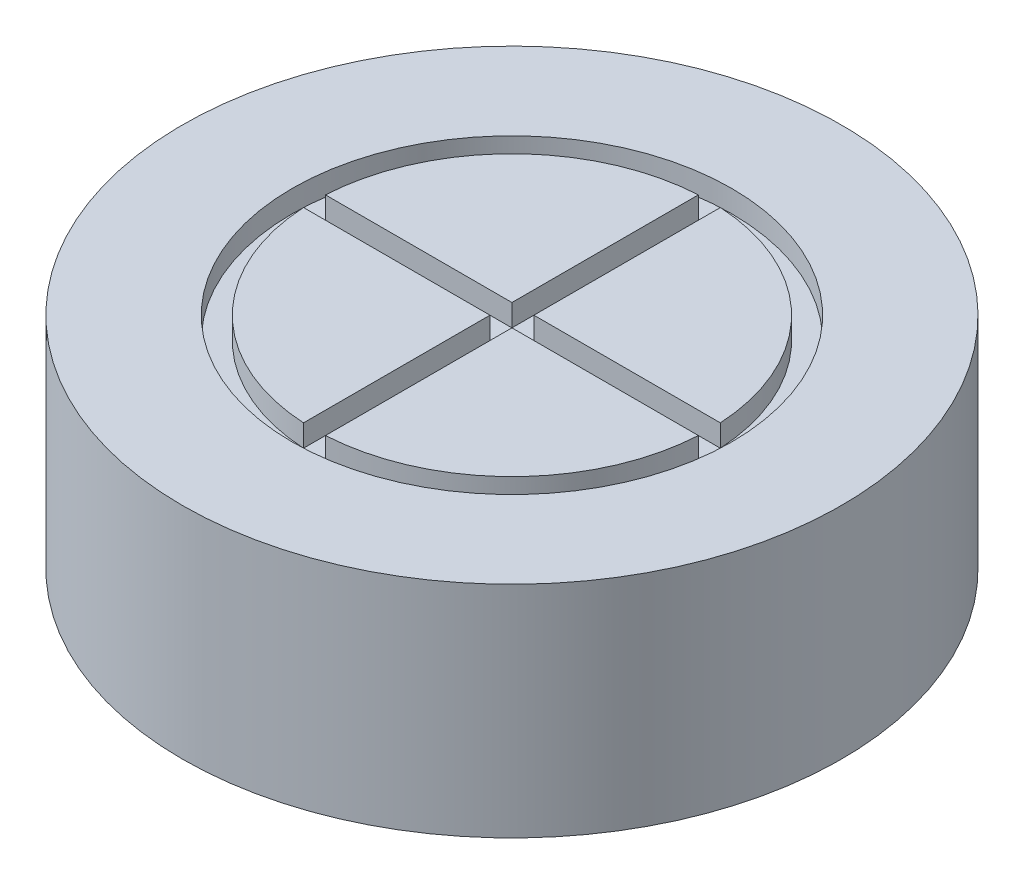
from build123d import *

# Parameters (mm, degrees)
SKETCH1_R           = 15
BOSS_EXTRUDE1_DEPTH = 10
SKETCH2_R           = 10
CUT_EXTRUDE1_DEPTH  = 1


with BuildPart() as part:
    # Sketch1 → Boss-Extrude1 (new body)
    with BuildSketch(Plane(origin=(0, 0, 0), x_dir=(1, 0, 0), z_dir=(0, 1, 0))):
        Circle(SKETCH1_R)
    extrude(amount=BOSS_EXTRUDE1_DEPTH)

    # Sketch3 → Cut-Revolve1 (revolve, cut)
    with BuildSketch(Plane(origin=(0, 0, 0), x_dir=(-1, 0, 0), z_dir=(0, -1, 0))):
        with BuildLine():
            Line((0, 5), (0, -5))
            ThreePointArc((0, -5), (5, 0), (0, 5))
        make_face()
    revolve(axis=Axis((0, 0, -5), (0, 0, 1)), mode=Mode.SUBTRACT)

    # Sketch2 → Cut-Extrude1 (cut)
    with BuildSketch(Plane(origin=(0, 10, 0), x_dir=(1, 0, 0), z_dir=(0, 1, 0))):
        Circle(SKETCH2_R)
        with BuildLine():
            Line((-0.5, -0.499807062), (-0.5, -8.986100378))
            ThreePointArc((-0.5, -8.986100378), (-6.36402935, -6.363892711), (-8.986111111, -0.499807062))
            Line((-8.986111111, -0.499807062), (-0.5, -0.499807062))
        make_face(mode=Mode.SUBTRACT)
        with BuildLine():
            Line((0.499807062, 8.986111111), (0.499807062, 0.499807062))
            Line((0.499807062, 0.499807062), (8.986111111, 0.499807062))
            ThreePointArc((8.986111111, 0.499807062), (6.363961031, 6.363961031), (0.499807062, 8.986111111))
        make_face(mode=Mode.SUBTRACT)
        with BuildLine():
            Line((-0.5, 8.986100378), (-0.5, 0.499807062))
            Line((-0.5, 0.499807062), (-8.986111111, 0.499807062))
            ThreePointArc((-8.986111111, 0.499807062), (-6.36402935, 6.363892711), (-0.5, 8.986100378))
        make_face(mode=Mode.SUBTRACT)
        with BuildLine():
            Line((8.986111111, -0.499807062), (0.499807062, -0.499807062))
            Line((0.499807062, -0.499807062), (0.499807062, -8.986111111))
            ThreePointArc((0.499807062, -8.986111111), (6.363961031, -6.363961031), (8.986111111, -0.499807062))
        make_face(mode=Mode.SUBTRACT)
    extrude(amount=-CUT_EXTRUDE1_DEPTH, mode=Mode.SUBTRACT)


solid = part.part
